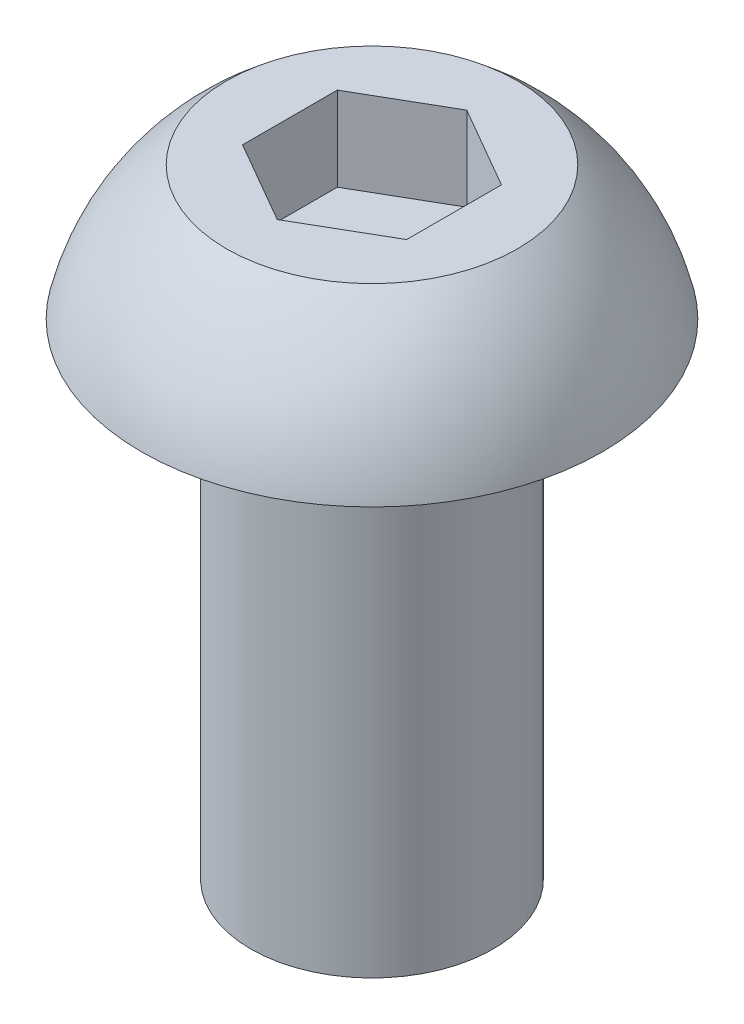
from build123d import *

# Parameters (mm, degrees)
CUT_EXTRUDE_1_DEPTH = 1.04
FILLET_1_R          = 0.1


with BuildPart() as part:
    # 草图1 → 旋转1 (revolve)
    with BuildSketch(Plane.XY):
        with BuildLine():
            Line((0, 2.304545455), (-1.8, 2.304545455))
            ThreePointArc((-1.8, 2.304545455), (-2.467032631, 1.569929856), (-2.85, 0.654545455))
            Line((-2.85, 0.654545455), (-1.5, 0.654545455))
            Line((-1.5, 0.654545455), (-1.5, -5.345454545))
            Line((-1.5, -5.345454545), (0, -5.345454545))
            Line((0, -5.345454545), (0, 2.304545455))
        make_face()
    revolve(axis=Axis((0, 0, 0), (0, 1, 0)))

    # 草图2 → 切除-拉伸1 (cut)
    with BuildSketch(Plane(origin=(0, 2.304545455, 0), x_dir=(1, 0, 0), z_dir=(0, 1, 0))):
        Polygon((0, -1.172021046), (1.015, -0.586010523), (1.015, 0.586010523), (0, 1.172021046), (-1.015, 0.586010523), (-1.015, -0.586010523), align=None)
    extrude(amount=-CUT_EXTRUDE_1_DEPTH, mode=Mode.SUBTRACT)

    # 圆角1
    fillet_1_edges = [part.edges().sort_by_distance(p)[0] for p in [
        (1.5, 0.654545455, 0),
    ]]
    fillet(fillet_1_edges, radius=FILLET_1_R)


solid = part.part
